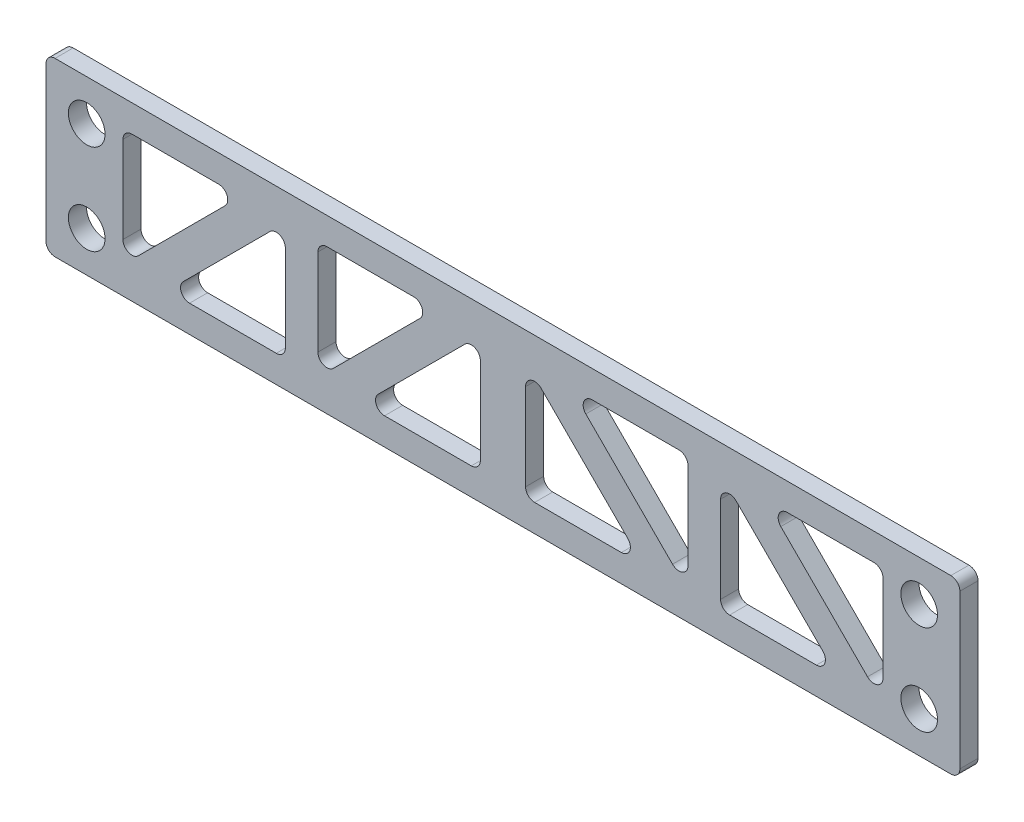
from build123d import *

# Parameters (mm, degrees)
SKETCH_1_W          = 101
SKETCH_1_H          = 19
SKETCH_1_R          = 2.025
EXTRUDE_1_DEPTH     = 2
CUT_EXTRUDE_1_DEPTH = 2
FILLET_1_R          = 1
FILLET_2_R          = 1


with BuildPart() as part:
    # 草图1 → 凸台-拉伸1 (new body)
    with BuildSketch(Plane.XY):
        Rectangle(SKETCH_1_W, SKETCH_1_H)
        with Locations((-46, 5)):
            Circle(SKETCH_1_R, mode=Mode.SUBTRACT)
        with Locations((46, 5)):
            Circle(SKETCH_1_R, mode=Mode.SUBTRACT)
        with Locations((46, -5)):
            Circle(SKETCH_1_R, mode=Mode.SUBTRACT)
        with Locations((-46, -5)):
            Circle(SKETCH_1_R, mode=Mode.SUBTRACT)
    extrude(amount=EXTRUDE_1_DEPTH)

    # 草图2 → 切除-拉伸1 (cut)
    with BuildSketch(Plane.XY.offset(2)):
        Polygon((-42, 6.5), (-42, -6.5), (-29, 6.5), align=None)
        Polygon((-24.050252532, 6.5), (-37.050252532, -6.5), (-24.050252532, -6.5), align=None)
        Polygon((-2.5, -6.5), (-2.5, 6.5), (-15.5, -6.5), align=None)
        Polygon((-7.449747468, 6.5), (-20.449747468, 6.5), (-20.449747468, -6.5), align=None)
        Polygon((42, -6.5), (29, 6.5), (42, 6.5), align=None)
        Polygon((37.050252532, -6.5), (24.050252532, -6.5), (24.050252532, 6.5), align=None)
        Polygon((20.449747468, -6.5), (7.449747468, 6.5), (20.449747468, 6.5), align=None)
        Polygon((15.5, -6.5), (2.5, -6.5), (2.5, 6.5), align=None)
    extrude(amount=-CUT_EXTRUDE_1_DEPTH, mode=Mode.SUBTRACT)

    # 圆角1
    fillet_1_edges = [part.edges().sort_by_distance(p)[0] for p in [
        (-20.449747468, -6.5, 1),
        (-20.449747468, 6.5, 1),
        (-7.449747468, 6.5, 1),
        (-15.5, -6.5, 1),
        (-2.5, 6.5, 1),
        (-2.5, -6.5, 1),
        (42, 6.5, 1),
        (42, -6.5, 1),
        (29, 6.5, 1),
        (-24.050252532, 6.5, 1),
        (-24.050252532, -6.5, 1),
        (-37.050252532, -6.5, 1),
        (2.5, 6.5, 1),
        (15.5, -6.5, 1),
        (2.5, -6.5, 1),
        (20.449747468, 6.5, 1),
        (20.449747468, -6.5, 1),
        (7.449747468, 6.5, 1),
        (24.050252532, 6.5, 1),
        (37.050252532, -6.5, 1),
        (24.050252532, -6.5, 1),
        (-42, 6.5, 1),
        (-29, 6.5, 1),
        (-42, -6.5, 1),
    ]]
    fillet(fillet_1_edges, radius=FILLET_1_R)

    # 圆角2
    fillet_2_edges = [part.edges().sort_by_distance(p)[0] for p in [
        (-50.5, 9.5, 1),
        (50.5, 9.5, 1),
        (50.5, -9.5, 1),
        (-50.5, -9.5, 1),
    ]]
    fillet(fillet_2_edges, radius=FILLET_2_R)


solid = part.part
